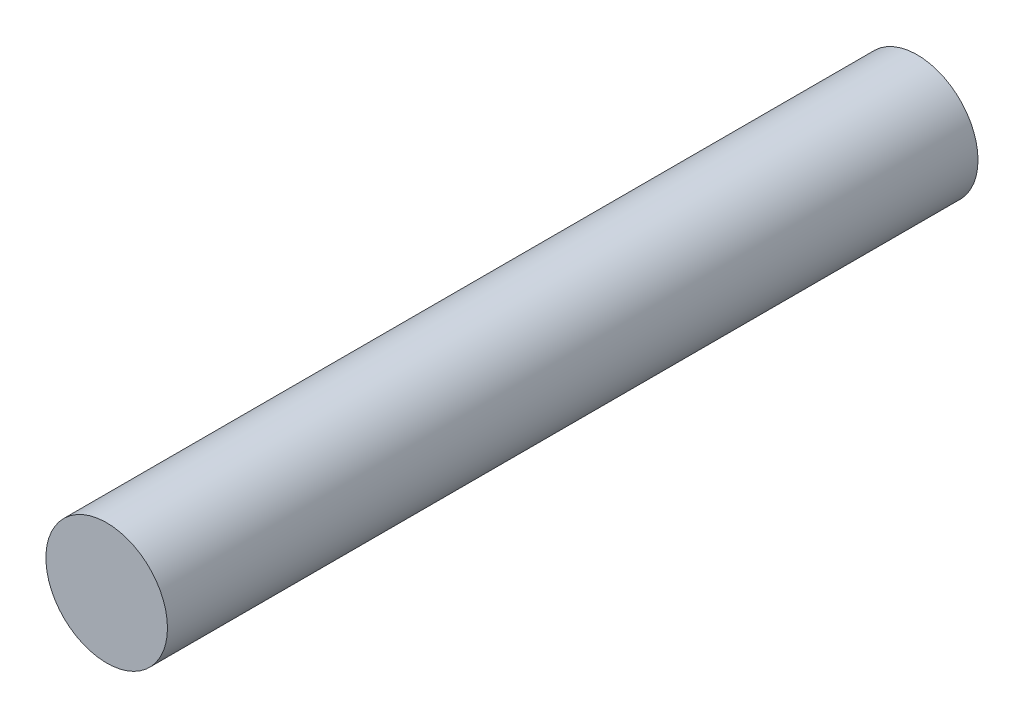
from build123d import *

# Parameters (mm, degrees)
SKETCH1_R           = 4.7625
BOSS_EXTRUDE1_DEPTH = 63.5


with BuildPart() as part:
    # Sketch1 → Boss-Extrude1 (new body)
    with BuildSketch(Plane.XY):
        Circle(SKETCH1_R)
    extrude(amount=BOSS_EXTRUDE1_DEPTH)


solid = part.part
